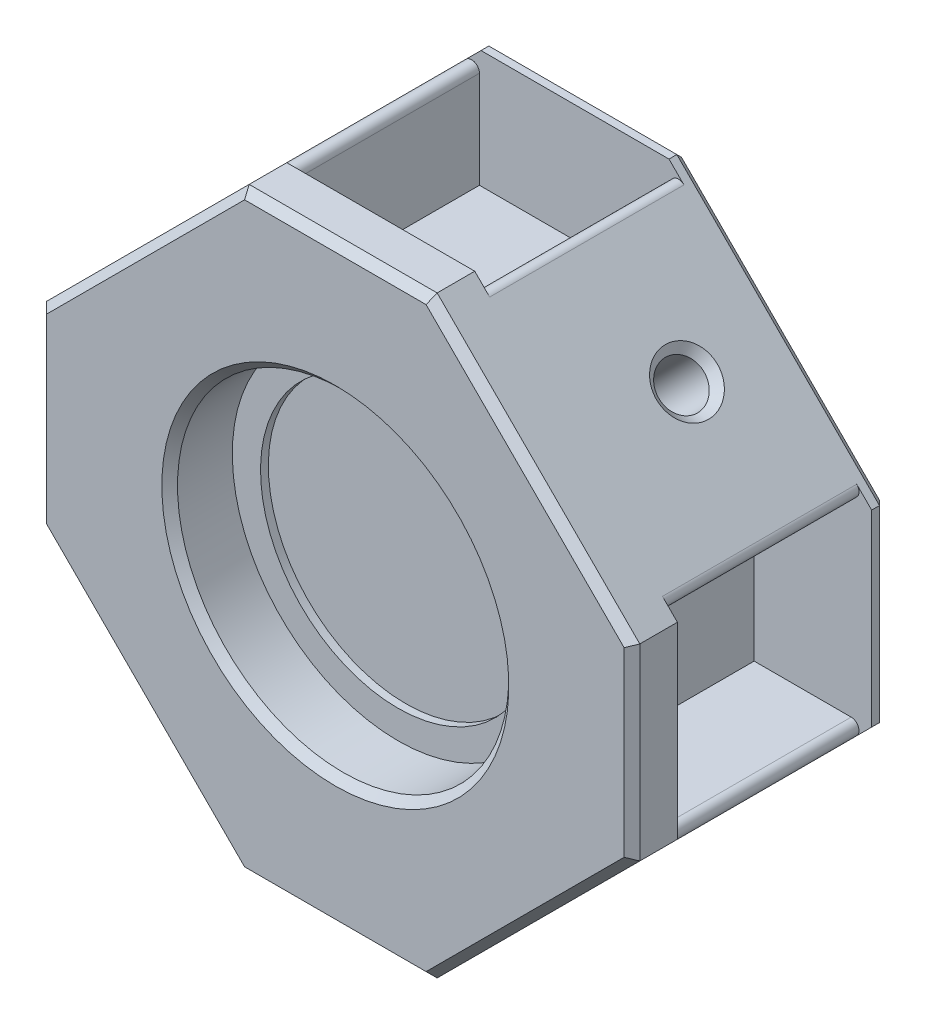
from build123d import *

# Parameters (mm, degrees)
SKIZZE1_W                          = 37.873435046
SKIZZE1_H                          = 37.873435047
AUFSATZ_LINEAR_AUSTRAGEN1_DEPTH    = 20
SKIZZE2_R                          = 10.575
SCHNITT_LINEAR_AUSTRAGEN1_DEPTH    = 4
SKIZZE3_W                          = 12
SKIZZE3_H                          = 12
SCHNITT_LINEAR_AUSTRAGEN3_DEPTH    = 7.5
VERRUNDUNG1_R                      = 8
KREISMUSTER1_COUNT                 = 4
SKIZZE4_R                          = 8.775
SCHNITT_LINEAR_AUSTRAGEN4_DEPTH    = 0.5
K_RPER_VERSCHIEBEN_KOPIEREN1_ANGLE = 90
SCHNITT_LINEAR_AUSTRAGEN5_DEPTH    = 21
SCHNITT_LINEAR_START               = -6
SKIZZE6_R                          = 1.45
SCHNITT_LINEAR_AUSTRAGEN6_DEPTH    = 16
KREISMUSTER2_COUNT                 = 4
SKIZZE7_W                          = 35.652729611
SKIZZE7_H                          = 9.273531579
SCHNITT_LINEAR_AUSTRAGEN8_DEPTH    = 45.41348481
SKIZZE8_W                          = 12.4
SKIZZE8_H                          = 12.2
SCHNITT_LINEAR_AUSTRAGEN9_DEPTH    = 7.5
KREISMUSTER11_COUNT                = 4
FASE1_SIZE                         = 0.5
VERRUNDUNG2_R                      = 0.5


with BuildPart() as part:
    # Skizze1 → Aufsatz-Linear austragen1 (new body)
    with BuildSketch(Plane(origin=(0, 0, 0), x_dir=(1, 0, 0), z_dir=(0, 1, 0))):
        with Locations((6, 12.936717524)):
            Rectangle(SKIZZE1_W, SKIZZE1_H)
    extrude(amount=AUFSATZ_LINEAR_AUSTRAGEN1_DEPTH)

    # Skizze2 → Schnitt-Linear austragen1 (cut)
    with BuildSketch(Plane.XZ):
        with Locations((6, -12.936717523)):
            Circle(SKIZZE2_R)
    extrude(amount=-SCHNITT_LINEAR_AUSTRAGEN1_DEPTH, mode=Mode.SUBTRACT)

    # Skizze3 → Schnitt-Linear austragen3 (cut)
    with BuildSketch(Plane.XY.offset(6)):
        with Locations((6, 9.2)):
            Rectangle(SKIZZE3_W, SKIZZE3_H)
    schnitt_linear_austragen3 = extrude(amount=-SCHNITT_LINEAR_AUSTRAGEN3_DEPTH, mode=Mode.SUBTRACT)

    # Verrundung1
    verrundung1_edges = [part.edges().sort_by_distance(p)[0] for p in [
        (24.936717523, 10, -31.873435047),
        (24.936717523, 10, 6),
        (-12.936717523, 10, 6),
        (-12.936717523, 10, -31.873435047),
    ]]
    fillet(verrundung1_edges, radius=VERRUNDUNG1_R)

    # Kreismuster1: Schnitt-Linear austragen3 ×4 about axis
    kreismuster1_axis = Axis((6, 0, -12.936717523), (0, 1, 0))
    for i in range(1, KREISMUSTER1_COUNT):
        add(schnitt_linear_austragen3.rotate(kreismuster1_axis, i * 360 / KREISMUSTER1_COUNT), mode=Mode.SUBTRACT)

    # Skizze4 → Schnitt-Linear austragen4 (cut)
    with BuildSketch(Plane.XZ.offset(-4)):
        with Locations((6, -12.936717523)):
            Circle(SKIZZE4_R)
    extrude(amount=-SCHNITT_LINEAR_AUSTRAGEN4_DEPTH, mode=Mode.SUBTRACT)


with BuildPart() as part_1:
    # Körper-Verschieben/Kopieren1: moved
    add(part.part.rotate(Axis((0, 10, -12.936717523), (-1, 0, 0)), K_RPER_VERSCHIEBEN_KOPIEREN1_ANGLE))

    # Skizze5 → Schnitt-Linear austragen5 (cut, through all)
    with BuildSketch(Plane.XY.offset(-2.936717523)):
        Polygon((0, 28.936717523), (-12.936717523, 16), (-12.936717523, 28.936717523), align=None)
        Polygon((24.936717523, 16), (24.936717523, 28.936717523), (12, 28.936717523), align=None)
        Polygon((12, -8.936717523), (24.936717523, 4), (24.936717523, -8.936717523), align=None)
        Polygon((-12.936717523, -8.936717523), (0, -8.936717523), (-12.936717523, 4), align=None)
    extrude(amount=-SCHNITT_LINEAR_AUSTRAGEN5_DEPTH, mode=Mode.SUBTRACT)

    # Skizze6 → Schnitt-Linear austragen6 (cut)
    with BuildSketch(Plane(origin=(-14.468358762, 14.468358762, 0), x_dir=(0.707106781, 0.707106781, 0), z_dir=(-0.707106781, 0.707106781, 0)).offset(SCHNITT_LINEAR_START)):
        with Locations((11.284238529, 12.936717523)):
            Circle(SKIZZE6_R)
    schnitt_linear_austragen6 = extrude(amount=SCHNITT_LINEAR_AUSTRAGEN6_DEPTH, mode=Mode.SUBTRACT)

    # Kreismuster2: Schnitt-Linear austragen6 ×4 about axis
    kreismuster2_axis = Axis((6, 10, 0), (0, 0, 1))
    for i in range(1, KREISMUSTER2_COUNT):
        add(schnitt_linear_austragen6.rotate(kreismuster2_axis, i * 360 / KREISMUSTER2_COUNT), mode=Mode.SUBTRACT)

    # Skizze7 → Schnitt-Linear austragen8 (cut, through all)
    with BuildSketch(Plane(origin=(20.468358762, 20.468358762, 0), x_dir=(0.707106781, -0.707106781, 0), z_dir=(0.707106781, 0.707106781, 0))):
        with Locations((-3.021869868, 23.873483313)):
            Rectangle(SKIZZE7_W, SKIZZE7_H)
    extrude(amount=-SCHNITT_LINEAR_AUSTRAGEN8_DEPTH, mode=Mode.SUBTRACT)

    # Skizze8 → Schnitt-Linear austragen9 (cut)
    with BuildSketch(Plane.ZY.offset(12.936717523)):
        with Locations((-12.036717523, 10)):
            Rectangle(SKIZZE8_W, SKIZZE8_H)
    schnitt_linear_austragen9 = extrude(amount=-SCHNITT_LINEAR_AUSTRAGEN9_DEPTH, mode=Mode.SUBTRACT)

    # Kreismuster11: Schnitt-Linear austragen9 ×4 about axis
    kreismuster11_axis = Axis((6, 10, 0), (0, 0, 1))
    for i in range(1, KREISMUSTER11_COUNT):
        add(schnitt_linear_austragen9.rotate(kreismuster11_axis, i * 360 / KREISMUSTER11_COUNT), mode=Mode.SUBTRACT)

    # Fase1
    fase1_edges = [part_1.edges().sort_by_distance(p)[0] for p in [
        (-12.936717523, 10, -2.936717523),
        (6, -8.936717523, -2.936717523),
        (24.936717523, 10, -2.936717523),
        (6, 28.936717523, -2.936717523),
        (-6.468358762, -2.468358762, -2.936717523),
        (18.468358762, -2.468358762, -2.936717523),
        (18.468358762, 22.468358762, -2.936717523),
        (-4.575, 10, -2.936717523),
        (-6.468358762, 22.468358762, -2.936717523),
        (-7.51450201, 21.422215513, -12.936717523),
        (-5.422215513, -3.51450201, -12.936717523),
        (19.51450201, -1.422215513, -12.936717523),
        (17.422215513, 23.51450201, -12.936717523),
        (-6.468358762, 22.468358762, -19.236717523),
        (18.468358762, 22.468358762, -19.236717523),
        (18.468358762, -2.468358762, -19.236717523),
        (24.936717523, 10, -19.236717523),
        (6, 28.936717523, -19.236717523),
        (-12.936717523, 10, -19.236717523),
        (-6.468358762, -2.468358762, -19.236717523),
        (6, -8.936717523, -19.236717523),
    ]]
    chamfer(fase1_edges, length=FASE1_SIZE)

    # Verrundung2
    verrundung2_edges = [part_1.edges().sort_by_distance(p)[0] for p in [
        (-12.836717523, 16.1, -12.036717523),
        (-12.836717523, 3.9, -12.036717523),
        (-0.1, 28.836717523, -12.036717523),
        (12.1, 28.836717523, -12.036717523),
        (24.836717523, 16.1, -12.036717523),
        (-0.1, -8.836717523, -12.036717523),
        (24.836717523, 3.9, -12.036717523),
        (12.1, -8.836717523, -12.036717523),
    ]]
    fillet(verrundung2_edges, radius=VERRUNDUNG2_R)


solid = part_1.part
